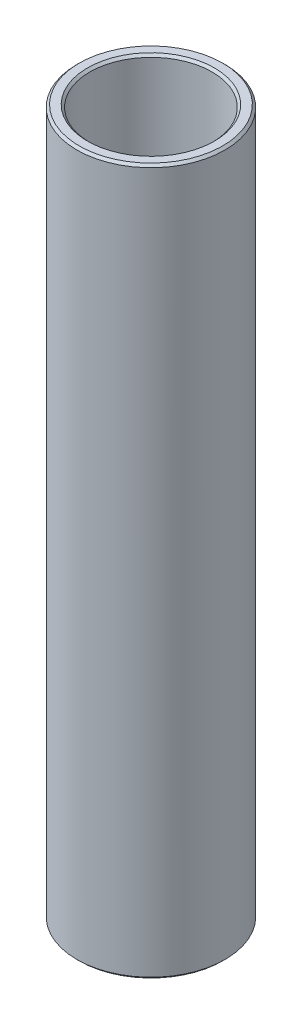
from build123d import *

# Parameters (mm, degrees)
SKETCH1_W     = 0.7
SKETCH1_H     = 38.1
CHAMFER1_SIZE = 0.127


with BuildPart() as part:
    # Sketch1 → Revolve1 (revolve)
    with BuildSketch(Plane.XY):
        with Locations((3.65, 0)):
            Rectangle(SKETCH1_W, SKETCH1_H)
    revolve(axis=Axis((0, 7.406764361, 0), (0, -1, 0)))

    # Chamfer1
    chamfer1_edges = [part.edges().sort_by_distance(p)[0] for p in [
        (-4, 19.05, 0),
        (-4, -19.05, 0),
        (-3.3, -19.05, 0),
        (-3.3, 19.05, 0),
    ]]
    chamfer(chamfer1_edges, length=CHAMFER1_SIZE)


solid = part.part
